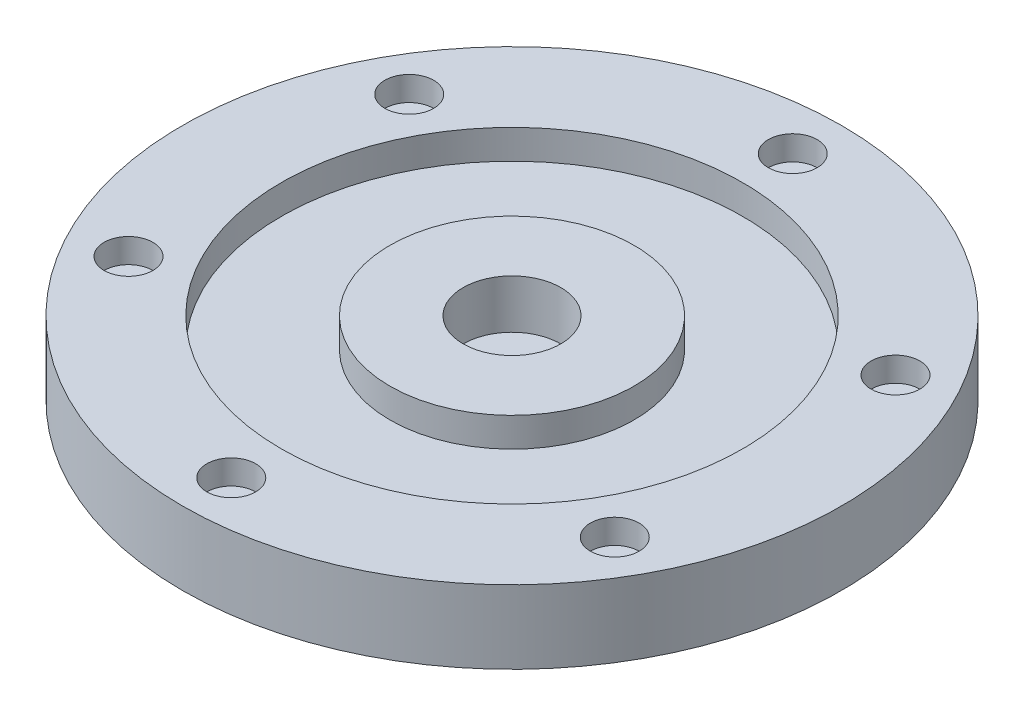
from build123d import *

# Parameters (mm, degrees)
SKETCH1_R           = 67.5
BOSS_EXTRUDE1_DEPTH = 15
SKETCH2_R           = 47.25
SKETCH2_R_2         = 25
CUT_EXTRUDE1_DEPTH  = 6
SKETCH3_R           = 10
CUT_EXTRUDE2_DEPTH  = 10
SKETCH5_R           = 2.5
CUT_EXTRUDE3_DEPTH  = 10
SKETCH6_R           = 2
CUT_EXTRUDE4_DEPTH  = 15
SKETCH7_R           = 5
CUT_EXTRUDE5_DEPTH  = 5


with BuildPart() as part:
    # Sketch1 → Boss-Extrude1 (new body)
    with BuildSketch(Plane(origin=(0, 0, 0), x_dir=(1, 0, 0), z_dir=(0, 1, 0))):
        Circle(SKETCH1_R)
    extrude(amount=BOSS_EXTRUDE1_DEPTH)

    # Sketch2 → Cut-Extrude1 (cut)
    with BuildSketch(Plane(origin=(0, 15, 0), x_dir=(1, 0, 0), z_dir=(0, 1, 0))):
        Circle(SKETCH2_R)
        Circle(SKETCH2_R_2, mode=Mode.SUBTRACT)
    extrude(amount=-CUT_EXTRUDE1_DEPTH, mode=Mode.SUBTRACT)

    # Sketch3 → Cut-Extrude2 (cut)
    with BuildSketch(Plane(origin=(0, 15, 0), x_dir=(1, 0, 0), z_dir=(0, 1, 0))):
        Circle(SKETCH3_R)
    extrude(amount=-CUT_EXTRUDE2_DEPTH, mode=Mode.SUBTRACT)

    # Sketch5 → Cut-Extrude3 (cut)
    with BuildSketch(Plane(origin=(0, 5, 0), x_dir=(1, 0, 0), z_dir=(0, 1, 0))):
        Circle(SKETCH5_R)
    extrude(amount=-CUT_EXTRUDE3_DEPTH, mode=Mode.SUBTRACT)

    # Sketch6 → Cut-Extrude4 (cut)
    with BuildSketch(Plane(origin=(0, 15, 0), x_dir=(1, 0, 0), z_dir=(0, 1, 0))):
        with Locations((0, 57.5)):
            Circle(SKETCH6_R)
        with Locations((49.796460718, 28.75)):
            Circle(SKETCH6_R)
        with Locations((49.796460718, -28.75)):
            Circle(SKETCH6_R)
        with Locations((0, -57.5)):
            Circle(SKETCH6_R)
        with Locations((-49.796460718, -28.75)):
            Circle(SKETCH6_R)
        with Locations((-49.796460718, 28.75)):
            Circle(SKETCH6_R)
    extrude(amount=-CUT_EXTRUDE4_DEPTH, mode=Mode.SUBTRACT)

    # Sketch7 → Cut-Extrude5 (cut)
    with BuildSketch(Plane(origin=(0, 15, 0), x_dir=(1, 0, 0), z_dir=(0, 1, 0))):
        with Locations((0, 57.5)):
            Circle(SKETCH7_R)
        with Locations((49.796460718, 28.75)):
            Circle(SKETCH7_R)
        with Locations((49.796460718, -28.75)):
            Circle(SKETCH7_R)
        with Locations((0, -57.5)):
            Circle(SKETCH7_R)
        with Locations((-49.796460718, -28.75)):
            Circle(SKETCH7_R)
        with Locations((-49.796460718, 28.75)):
            Circle(SKETCH7_R)
    extrude(amount=-CUT_EXTRUDE5_DEPTH, mode=Mode.SUBTRACT)


solid = part.part
